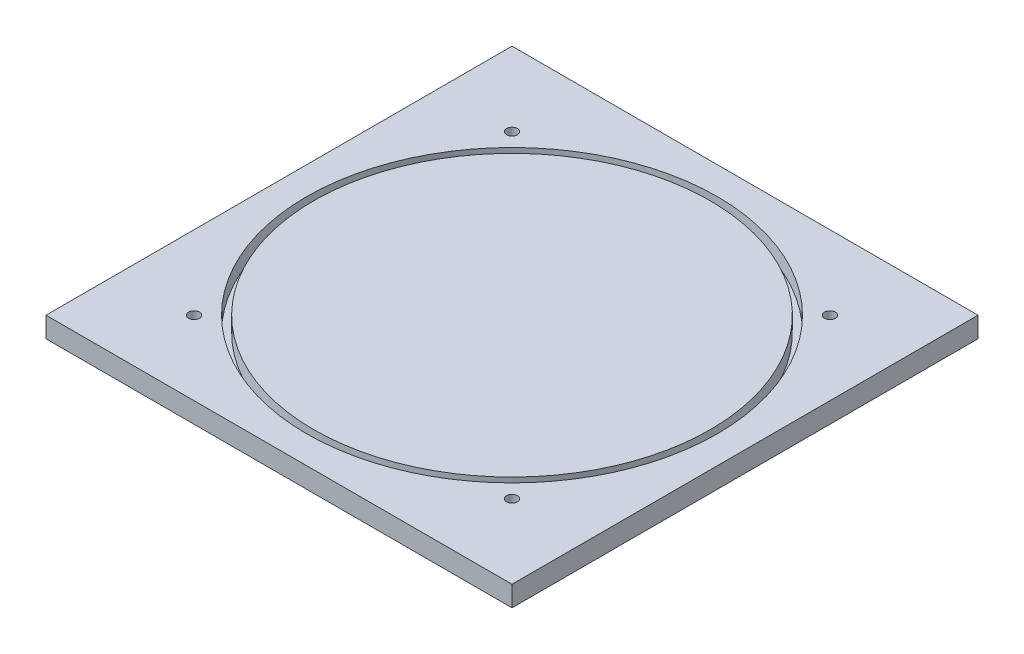
from build123d import *

# Parameters (mm, degrees)
SKETCH1_W               = 289.56
SKETCH1_H               = 289.56
BOSS_EXTRUDE1_DEPTH     = 12.7
SKETCH7_R               = 127.635
SKETCH7_R_2             = 123.19
CUT_EXTRUDE1_DEPTH      = 9.525
F_1_4_CLEARANCE_HOLE1_D = 6.7564
CIRPATTERN1_COUNT       = 4


with BuildPart() as part:
    # Sketch1 → Boss-Extrude1 (new body)
    with BuildSketch(Plane(origin=(0, 0, 0), x_dir=(1, 0, 0), z_dir=(0, 1, 0))):
        Rectangle(SKETCH1_W, SKETCH1_H)
    extrude(amount=BOSS_EXTRUDE1_DEPTH)

    # Sketch7 → Cut-Extrude1 (cut)
    with BuildSketch(Plane(origin=(0, 12.7, 0), x_dir=(1, 0, 0), z_dir=(0, 1, 0))):
        Circle(SKETCH7_R)
        Circle(SKETCH7_R_2, mode=Mode.SUBTRACT)
    extrude(amount=-CUT_EXTRUDE1_DEPTH, mode=Mode.SUBTRACT)

    # 1/4 Clearance Hole1 (through all)
    with Locations(Plane(origin=(0, 0, 0), x_dir=(-1, 0, 0), z_dir=(0, -1, 0))):
        with Locations((98.782817332, -98.782817332)):
            f_1_4_clearance_hole1 = Hole(F_1_4_CLEARANCE_HOLE1_D / 2)

    # CirPattern1: 1/4 Clearance Hole1 ×4 about axis
    cirpattern1_axis = Axis((0, 0, 0), (0, 1, 0))
    for i in range(1, CIRPATTERN1_COUNT):
        add(f_1_4_clearance_hole1.rotate(cirpattern1_axis, i * 360 / CIRPATTERN1_COUNT), mode=Mode.SUBTRACT)


solid = part.part
